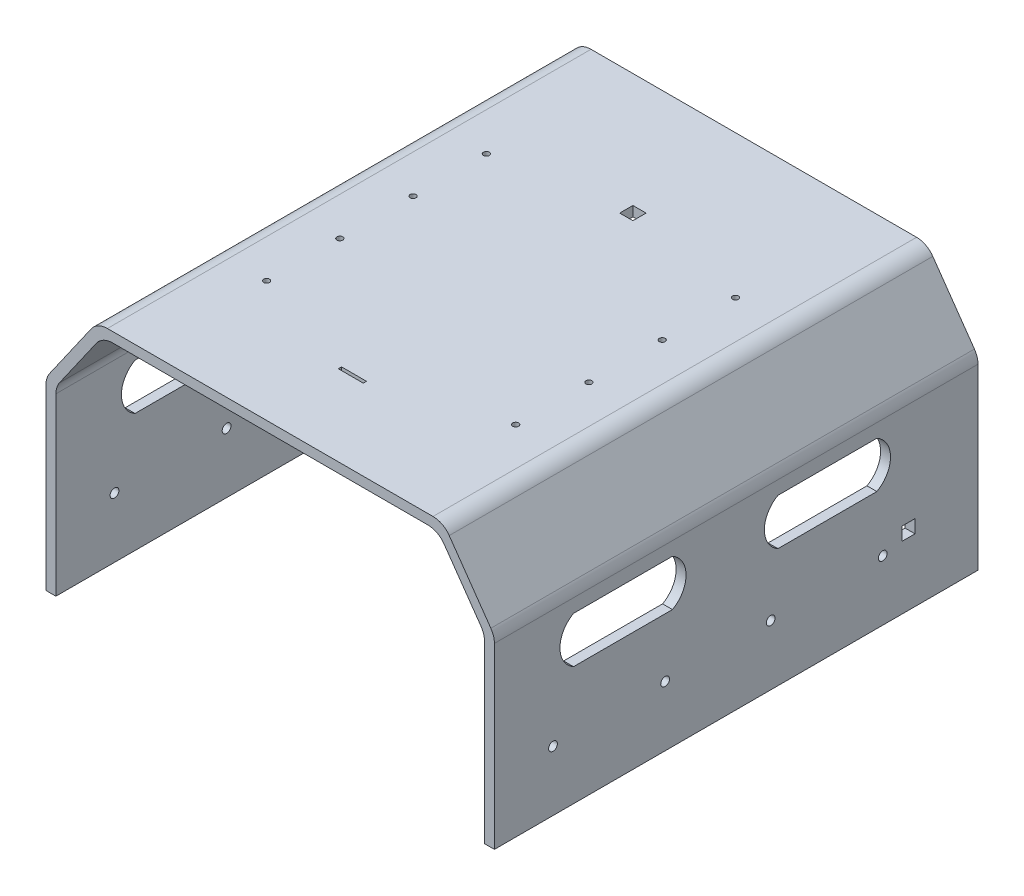
from build123d import *

# Parameters (mm, degrees)
SALIENTE_EXTRUIR1_DEPTH     = 700
REDONDEO1_R                 = 30
CORTAR_EXTRUIR7_DEPTH       = 1052.205028246
ESCALA1_SCALE               = 0.6
ESCALA2_SCALE               = 0.75
CROQUIS17_R                 = 2
CORTAR_EXTRUIR8_DEPTH       = 10
CROQUIS18_R                 = 3
CORTAR_EXTRUIR9_DEPTH       = 677.637223959
CROQUIS19_W                 = 17
CROQUIS19_H                 = 2.2
CORTAR_EXTRUIR10_DEPTH      = 730.049540368
CROQUIS21_W                 = 9
CROQUIS21_H                 = 9
CORTAR_EXTRUIR11_DEPTH      = 674.611531483
CORTAR_EXTRUIR11_DEPTH_BACK = 674.611531483
CROQUIS22_W                 = 9
CROQUIS22_H                 = 9
CORTAR_EXTRUIR12_DEPTH      = 728.451307564
SALIENTE_EXTRUIR3_DEPTH     = 15
CROQUIS26_R                 = 2
CORTAR_EXTRUIR13_DEPTH      = 678.196192286


with BuildPart() as part:
    # Croquis1 → Saliente-Extruir1 (new body)
    with BuildSketch(Plane.XY):
        Polygon((0, 0), (0, 280), (77.5, 390.681470523), (602.5, 390.681470523), (680, 280), (680, 0), (665, 0), (665, 275.270518167), (594.691494242, 375.681470523), (85.308505758, 375.681470523), (15, 275.270518167), (15, 0), align=None)
    extrude(amount=SALIENTE_EXTRUIR1_DEPTH)

    # Redondeo1
    redondeo1_edges = [part.edges().sort_by_distance(p)[0] for p in [
        (0, 280, 350),
        (77.5, 390.681470523, 350),
        (602.5, 390.681470523, 350),
        (680, 280, 350),
        (665, 275.270518167, 350),
        (594.691494242, 375.681470523, 350),
        (85.308505758, 375.681470523, 350),
        (15, 275.270518167, 350),
    ]]
    fillet(redondeo1_edges, radius=REDONDEO1_R)

    # Croquis16 → Cortar-Extruir7 (cut, through all)
    with BuildSketch(Plane(origin=(680, 0, 0), x_dir=(0, 0, -1), z_dir=(1, 0, 0))):
        with BuildLine():
            Line((-430, 180), (-580, 180))
            ThreePointArc((-580, 180), (-600.635083269, 215), (-580, 250))
            Line((-580, 250), (-430, 250))
            ThreePointArc((-430, 250), (-409.364916731, 215), (-430, 180))
        make_face()
    cortar_extruir7 = extrude(amount=-CORTAR_EXTRUIR7_DEPTH, mode=Mode.SUBTRACT)

    # Simetría1: Cortar-Extruir7 across plane
    add(cortar_extruir7.mirror(Plane.XY.offset(350)), mode=Mode.SUBTRACT)


with BuildPart() as part_1:
    # Escala1: scaled about (340, 274.108807771, 350)
    add(part.part.scale(ESCALA1_SCALE).moved(Location((136, 109.643523108, 140))))


with BuildPart() as part_2:
    # Escala2: scaled about (340, 274.108807771, 350)
    add(part_1.part.scale(ESCALA2_SCALE).moved(Location((85, 68.527201943, 87.5))))

    # Croquis17 → Cortar-Extruir8 (cut)
    with BuildSketch(Plane.XZ.offset(-319.816506009)):
        with Locations(Location((255.002655182, 425, 0), (0, 0, 270))):
            Circle(CROQUIS17_R)
        with Locations(Location((255.002655182, 375, 0), (0, 0, 270))):
            Circle(CROQUIS17_R)
        with Locations(Location((425.002655182, 425, 0), (0, 0, 270))):
            Circle(CROQUIS17_R)
        with Locations(Location((255.002655182, 325, 0), (0, 0, 270))):
            Circle(CROQUIS17_R)
        with Locations(Location((255.002655182, 275, 0), (0, 0, 270))):
            Circle(CROQUIS17_R)
        with Locations(Location((425.002655182, 375, 0), (0, 0, 270))):
            Circle(CROQUIS17_R)
        with Locations(Location((425.002655182, 325, 0), (0, 0, 270))):
            Circle(CROQUIS17_R)
        with Locations(Location((425.002655182, 275, 0), (0, 0, 270))):
            Circle(CROQUIS17_R)
    extrude(amount=-CORTAR_EXTRUIR8_DEPTH, mode=Mode.SUBTRACT)

    # Croquis18 → Cortar-Extruir9 (cut, through all)
    with BuildSketch(Plane(origin=(493, 0, 0), x_dir=(0, 0, -1), z_dir=(1, 0, 0))):
        with Locations(Location((-467.5, 191.759844274, 0), (0, 0, 90))):
            Circle(CROQUIS18_R)
        with Locations(Location((-391, 191.759844274, 0), (0, 0, 90))):
            Circle(CROQUIS18_R)
        with Locations(Location((-319, 191.759844274, 0), (0, 0, 90))):
            Circle(CROQUIS18_R)
        with Locations(Location((-242.5, 191.759844274, 0), (0, 0, 90))):
            Circle(CROQUIS18_R)
    extrude(amount=-CORTAR_EXTRUIR9_DEPTH, mode=Mode.SUBTRACT)

    # Croquis19 → Cortar-Extruir10 (cut, through all)
    with BuildSketch(Plane(origin=(0, 326.566506009, 0), x_dir=(1, 0, 0), z_dir=(0, 1, 0))):
        with Locations((340, -451.4)):
            Rectangle(CROQUIS19_W, CROQUIS19_H)
    extrude(amount=-CORTAR_EXTRUIR10_DEPTH, mode=Mode.SUBTRACT)

    # Croquis21 → Cortar-Extruir11 (cut, two sides)
    with BuildSketch(Plane.ZY.offset(-486.25)) as cortar_extruir11_sk:
        with Locations((225, 198.259844274)):
            Rectangle(CROQUIS21_W, CROQUIS21_H)
    extrude(amount=CORTAR_EXTRUIR11_DEPTH, mode=Mode.SUBTRACT)
    extrude(cortar_extruir11_sk.sketch, amount=-CORTAR_EXTRUIR11_DEPTH_BACK, mode=Mode.SUBTRACT)

    # Croquis22 → Cortar-Extruir12 (cut, through all)
    with BuildSketch(Plane.XZ.offset(-319.816506009)):
        with Locations((340, 260)):
            Rectangle(CROQUIS22_W, CROQUIS22_H)
    extrude(amount=-CORTAR_EXTRUIR12_DEPTH, mode=Mode.SUBTRACT)

    # Croquis24 → Saliente-Extruir3 (add)
    with BuildSketch(Plane(origin=(0, 0, 192.5), x_dir=(-1, 0, 0), z_dir=(0, 0, -1))):
        with BuildLine():
            Line((-187, 272.503310624), (-187, 150.759844274))
            Line((-187, 150.759844274), (-207, 150.759844274))
            Line((-207, 150.759844274), (-207, 270.453868496))
            Line((-207, 270.453868496), (-232.286341011, 306.566506009))
            Line((-232.286341011, 306.566506009), (-447.713658989, 306.566506009))
            Line((-447.713658989, 306.566506009), (-473, 270.453868496))
            Line((-473, 270.453868496), (-473, 150.759844274))
            Line((-473, 150.759844274), (-493, 150.759844274))
            Line((-493, 150.759844274), (-493, 272.503310624))
            ThreePointArc((-493, 272.503310624), (-492.375178835, 276.562838918), (-490.558552598, 280.246592515))
            Line((-490.558552598, 280.246592515), (-462.155897415, 320.8097879))
            ThreePointArc((-462.155897415, 320.8097879), (-457.330951096, 325.041152257), (-451.097344818, 326.566506009))
            Line((-451.097344818, 326.566506009), (-228.902655182, 326.566506009))
            ThreePointArc((-228.902655182, 326.566506009), (-222.669048904, 325.041152257), (-217.844102585, 320.8097879))
            Line((-217.844102585, 320.8097879), (-189.441447402, 280.246592515))
            ThreePointArc((-189.441447402, 280.246592515), (-187.624821165, 276.562838918), (-187, 272.503310624))
        make_face()
    extrude(amount=SALIENTE_EXTRUIR3_DEPTH)

    # Croquis26 → Cortar-Extruir13 (cut, through all)
    with BuildSketch(Plane(origin=(0, 0, 177.5), x_dir=(-1, 0, 0), z_dir=(0, 0, -1))):
        with Locations((-385, 314.566506009)):
            Circle(CROQUIS26_R)
        with Locations((-295, 314.566506009)):
            Circle(CROQUIS26_R)
        with Locations((-481, 160.759844274)):
            Circle(CROQUIS26_R)
        with Locations((-199, 160.759844274)):
            Circle(CROQUIS26_R)
        with Locations((-199, 240.759844274)):
            Circle(CROQUIS26_R)
        with Locations((-481, 240.759844274)):
            Circle(CROQUIS26_R)
    extrude(amount=-CORTAR_EXTRUIR13_DEPTH, mode=Mode.SUBTRACT)


solid = part_2.part
